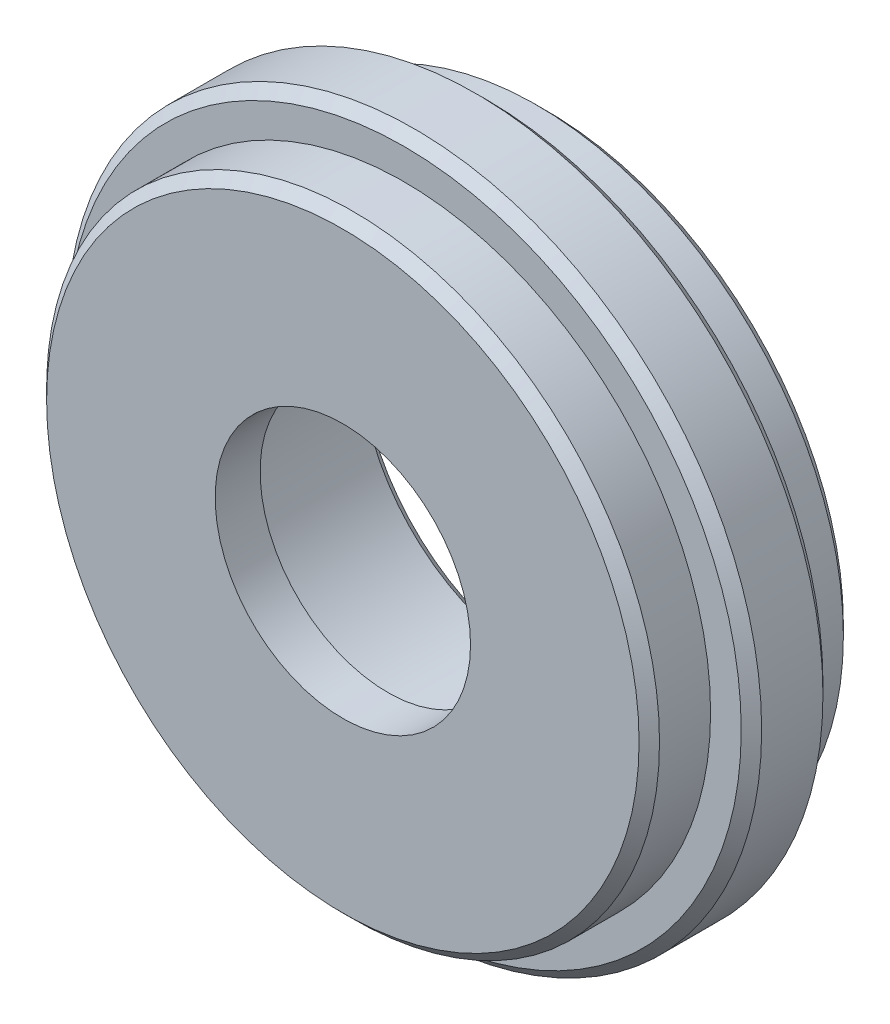
from build123d import *

# Parameters (mm, degrees)
SKETCH1_R           = 19.05
SKETCH1_R_2         = 10.9873
BOSS_EXTRUDE1_DEPTH = 6.35
SKETCH2_R           = 21.59
SKETCH2_R_2         = 10.9873
BOSS_EXTRUDE2_DEPTH = 2.54
SKETCH3_R           = 10.9873
SKETCH3_R_2         = 7.9375
BOSS_EXTRUDE3_DEPTH = 2.794
CHAMFER1_SIZE       = 0.635
CHAMFER2_SIZE       = 0.635


with BuildPart() as part:
    # Sketch1 → Boss-Extrude1 (new body, symmetric)
    with BuildSketch(Plane.XY):
        Circle(SKETCH1_R)
        Circle(SKETCH1_R_2, mode=Mode.SUBTRACT)
    extrude(amount=BOSS_EXTRUDE1_DEPTH, both=True)

    # Sketch2 → Boss-Extrude2 (add, symmetric)
    with BuildSketch(Plane.XY):
        Circle(SKETCH2_R)
        Circle(SKETCH2_R_2, mode=Mode.SUBTRACT)
    extrude(amount=BOSS_EXTRUDE2_DEPTH, both=True)

    # Sketch3 → Boss-Extrude3 (add)
    with BuildSketch(Plane.XY.offset(6.35)):
        Circle(SKETCH3_R)
        Circle(SKETCH3_R_2, mode=Mode.SUBTRACT)
    extrude(amount=-BOSS_EXTRUDE3_DEPTH)

    # Chamfer1
    chamfer1_edges = [part.edges().sort_by_distance(p)[0] for p in [
        (-21.59, 0, 2.54),
        (-21.59, 0, -2.54),
        (-19.05, 0, -6.35),
        (-19.05, 0, 6.35),
    ]]
    chamfer(chamfer1_edges, length=CHAMFER1_SIZE)

    # Chamfer2
    chamfer2_edges = [part.edges().sort_by_distance(p)[0] for p in [
        (-10.9873, 0, -6.35),
    ]]
    chamfer(chamfer2_edges, length=CHAMFER2_SIZE)


solid = part.part
